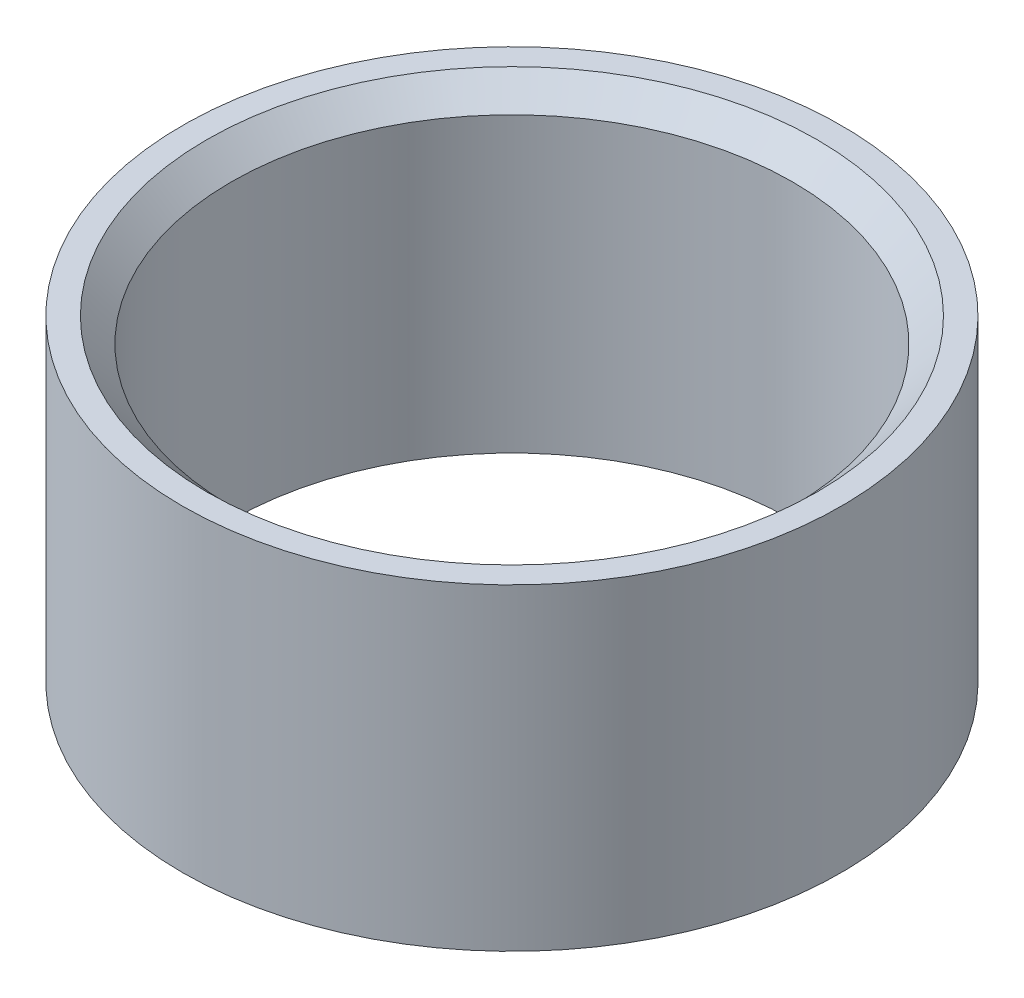
from build123d import *

# Parameters (mm, degrees)
SKETCH1_R                            = 1.35
BOSS_EXTRUDE1_DEPTH                  = 1.3
F_2_3_2_3_DIAMETER_HOLE1_D           = 2.3
F_2_3_2_3_DIAMETER_HOLE1_DEPTH       = 1.3
F_2_3_2_3_DIAMETER_HOLE1_CSINK_D     = 2.5
F_2_3_2_3_DIAMETER_HOLE1_CSINK_ANGLE = 90


with BuildPart() as part:
    # Sketch1 → Boss-Extrude1 (new body)
    with BuildSketch(Plane(origin=(0, 0, 0), x_dir=(1, 0, 0), z_dir=(0, 1, 0))):
        Circle(SKETCH1_R)
    extrude(amount=BOSS_EXTRUDE1_DEPTH)

    # Ø2.3 (2.3) Diameter Hole1
    with Locations(Plane(origin=(0, 1.3, 0), x_dir=(1, 0, 0), z_dir=(0, 1, 0))):
        with Locations((0, 0)):
            CounterSinkHole(F_2_3_2_3_DIAMETER_HOLE1_D / 2, F_2_3_2_3_DIAMETER_HOLE1_CSINK_D / 2, depth=F_2_3_2_3_DIAMETER_HOLE1_DEPTH, counter_sink_angle=F_2_3_2_3_DIAMETER_HOLE1_CSINK_ANGLE)


solid = part.part
